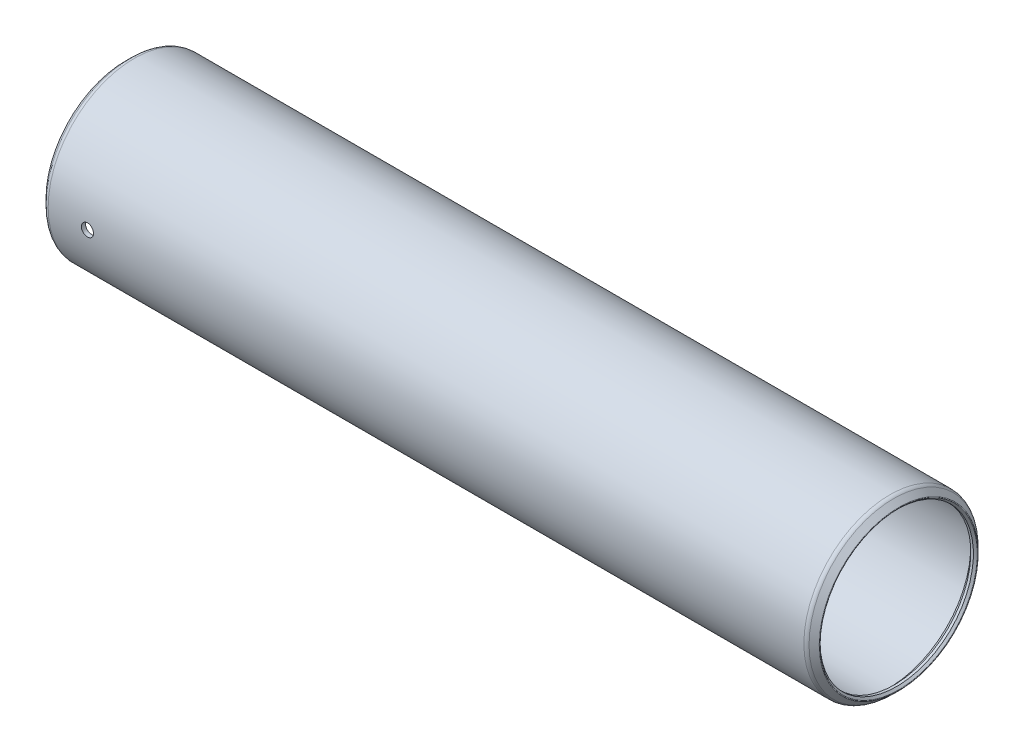
from build123d import *

# Parameters (mm, degrees)
SKETCH2_R          = 1.1938
CUT_EXTRUDE1_DEPTH = 16.84655


with BuildPart() as part:
    # Sketch1 → Revolve1 (revolve)
    with BuildSketch(Plane.XY):
        with BuildLine():
            Line((-0.882617928, 15.379667928), (-0.508, 15.00505))
            Line((-0.508, 15.00505), (0, 15.00505))
            Line((0, 15.00505), (1.016, 16.02105))
            Line((1.016, 16.02105), (148.5392, 16.02105))
            Line((148.5392, 16.02105), (149.5552, 15.00505))
            Line((149.5552, 15.00505), (150.0632, 15.00505))
            Line((150.0632, 15.00505), (150.437817928, 15.379667928))
            ThreePointArc((150.437817928, 15.379667928), (150.475015367, 15.46947049), (150.437817928, 15.559273051))
            Line((150.437817928, 15.559273051), (149.44812049, 16.54897049))
            ThreePointArc((149.44812049, 16.54897049), (149.118506367, 16.769211605), (148.7297, 16.84655))
            Line((148.7297, 16.84655), (0.8255, 16.84655))
            ThreePointArc((0.8255, 16.84655), (0.436693633, 16.769211605), (0.10707951, 16.54897049))
            Line((0.10707951, 16.54897049), (-0.882617928, 15.559273051))
            ThreePointArc((-0.882617928, 15.559273051), (-0.919815367, 15.46947049), (-0.882617928, 15.379667928))
        make_face()
    revolve(axis=Axis((149.5552, 0, 0), (-1, 0, 0)))

    # Sketch2 → Cut-Extrude1 (cut)
    with BuildSketch(Plane.XY):
        with Locations((8.509, 0)):
            Circle(SKETCH2_R)
    extrude(amount=CUT_EXTRUDE1_DEPTH, mode=Mode.SUBTRACT)


solid = part.part
